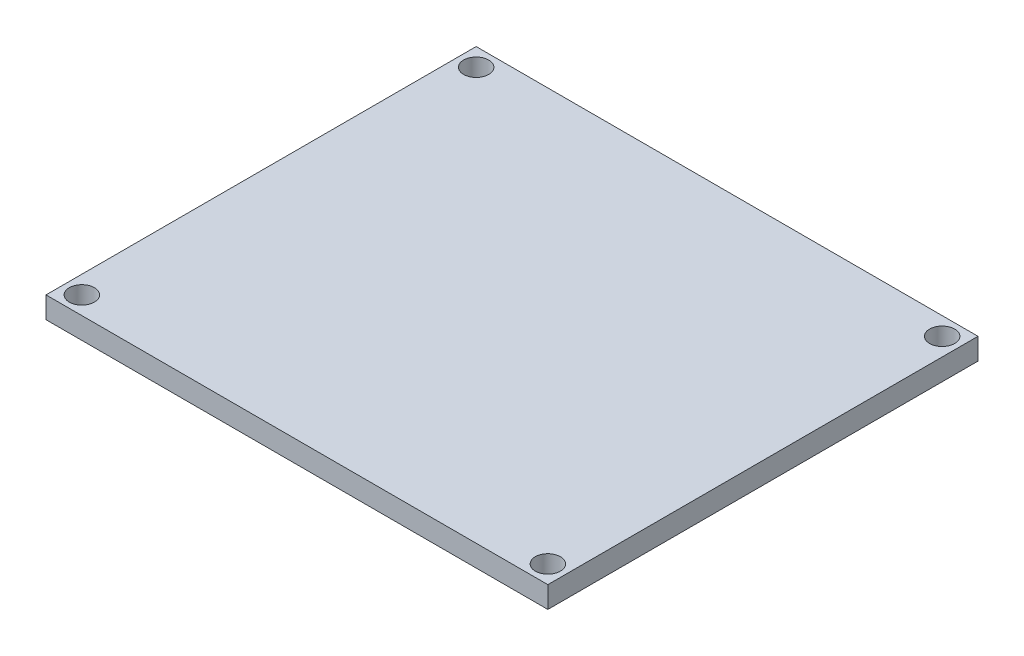
from build123d import *

# Parameters (mm, degrees)
SKETCH1_W           = 70
SKETCH1_H           = 60
BOSS_EXTRUDE1_DEPTH = 3
SKETCH2_R           = 1.75
CUT_EXTRUDE1_DEPTH  = 6


with BuildPart() as part:
    # Sketch1 → Boss-Extrude1 (new body)
    with BuildSketch(Plane(origin=(0, 0, 0), x_dir=(1, 0, 0), z_dir=(0, 1, 0))):
        with Locations((4.0625, 18.59375)):
            Rectangle(SKETCH1_W, SKETCH1_H)
    extrude(amount=BOSS_EXTRUDE1_DEPTH)

    # Sketch2 → Cut-Extrude1 (cut)
    with BuildSketch(Plane(origin=(0, 3, 0), x_dir=(1, 0, 0), z_dir=(0, 1, 0))):
        with Locations((-28.4375, 46.09375)):
            Circle(SKETCH2_R)
        with Locations((36.5625, 46.09375)):
            Circle(SKETCH2_R)
        with Locations((36.5625, -8.90625)):
            Circle(SKETCH2_R)
        with Locations((-28.4375, -8.90625)):
            Circle(SKETCH2_R)
    extrude(amount=-CUT_EXTRUDE1_DEPTH, mode=Mode.SUBTRACT)


solid = part.part
